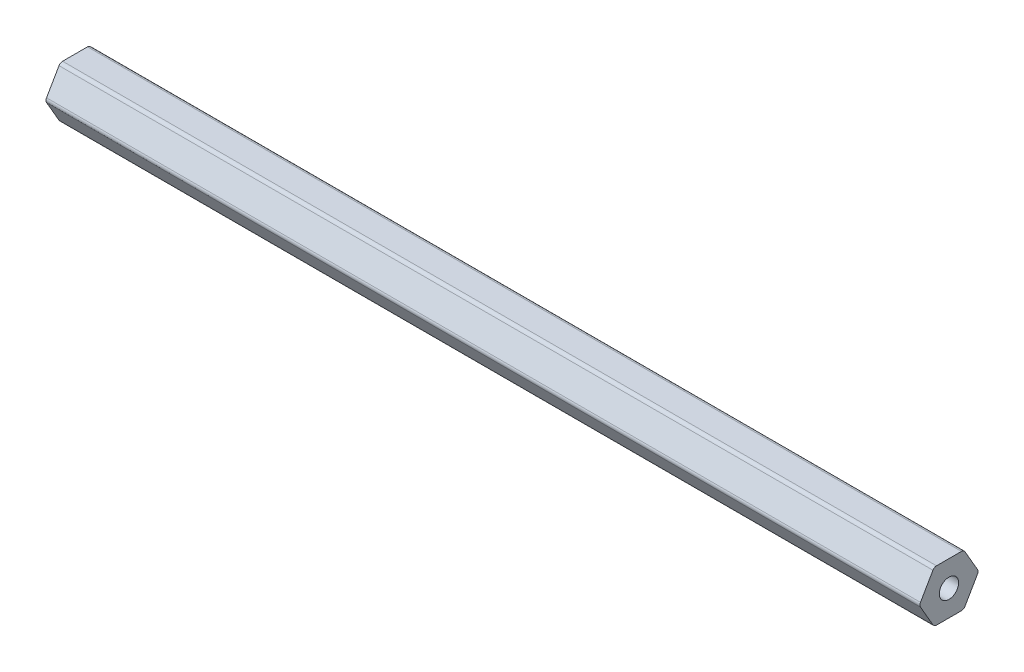
from build123d import *

# Parameters (mm, degrees)
SKETCH1_R           = 2.38125
BOSS_EXTRUDE1_DEPTH = 215.9


with BuildPart() as part:
    # Sketch1 → Boss-Extrude1 (new body)
    with BuildSketch(Plane(origin=(0, 0, 0), x_dir=(0, 0, -1), z_dir=(1, 0, 0))):
        with BuildLine():
            Line((7.039054482, 0.508), (3.959468146, 5.842))
            ThreePointArc((3.959468146, 5.842), (3.587586336, 6.21388181), (3.079586336, 6.35))
            Line((3.079586336, 6.35), (-3.079586336, 6.35))
            ThreePointArc((-3.079586336, 6.35), (-3.587586336, 6.21388181), (-3.959468146, 5.842))
            Line((-3.959468146, 5.842), (-7.039054482, 0.508))
            ThreePointArc((-7.039054482, 0.508), (-7.175172672, 0), (-7.039054482, -0.508))
            Line((-7.039054482, -0.508), (-3.959468146, -5.842))
            ThreePointArc((-3.959468146, -5.842), (-3.587586336, -6.21388181), (-3.079586336, -6.35))
            Line((-3.079586336, -6.35), (3.079586336, -6.35))
            ThreePointArc((3.079586336, -6.35), (3.587586336, -6.21388181), (3.959468146, -5.842))
            Line((3.959468146, -5.842), (7.039054482, -0.508))
            ThreePointArc((7.039054482, -0.508), (7.175172672, 0), (7.039054482, 0.508))
        make_face()
        Circle(SKETCH1_R, mode=Mode.SUBTRACT)
    extrude(amount=BOSS_EXTRUDE1_DEPTH)


solid = part.part
